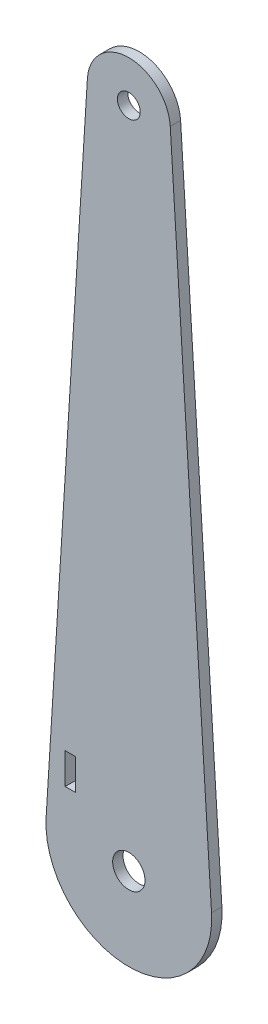
from build123d import *

# Parameters (mm, degrees)
SKETCH1_R           = 4.953
SKETCH1_R_2         = 3.5
SKETCH1_W           = 3.175
SKETCH1_H           = 9.525
BOSS_EXTRUDE1_DEPTH = 3.175


with BuildPart() as part:
    # Sketch1 → Boss-Extrude1 (new body)
    with BuildSketch(Plane.XY):
        with BuildLine():
            Line((-25.350535869, 1.58440246), (-12.7, 203.993746978))
            ThreePointArc((-12.7, 203.993746978), (0, 215.924780323), (12.7, 203.993746978))
            Line((12.7, 203.993746978), (25.350535869, 1.58440246))
            ThreePointArc((25.350535869, 1.58440246), (0, -25.4), (-25.350535869, 1.58440246))
        make_face()
        Circle(SKETCH1_R, mode=Mode.SUBTRACT)
        with Locations((0, 203.2)):
            Circle(SKETCH1_R_2, mode=Mode.SUBTRACT)
        with Locations((-17.9197, 17.4625)):
            Rectangle(SKETCH1_W, SKETCH1_H, mode=Mode.SUBTRACT)
    extrude(amount=BOSS_EXTRUDE1_DEPTH)


solid = part.part
